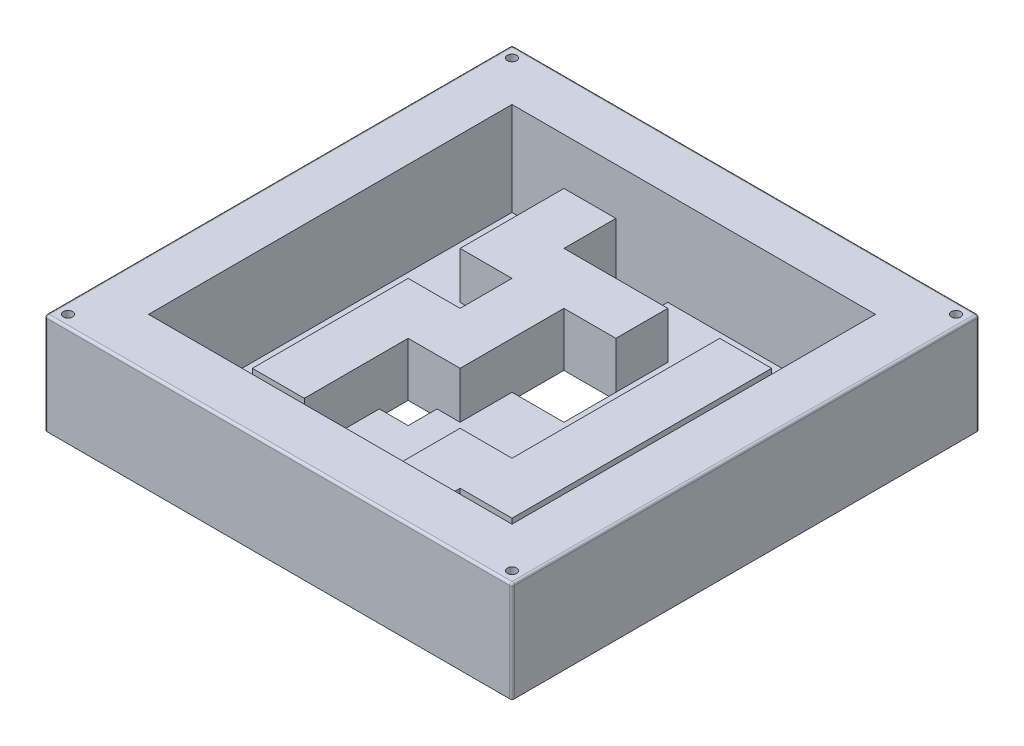
from build123d import *

# Parameters (mm, degrees)
ESQUISSE2_W             = 200
ESQUISSE2_H             = 200
BOSS_EXTRU_1_DEPTH      = 3
ESQUISSE3_W             = 200
ESQUISSE3_H             = 200
ESQUISSE3_W_2           = 155.54
ESQUISSE3_H_2           = 155.54
BOSS_EXTRU_2_DEPTH      = 40
BOSS_EXTRU_3_DEPTH      = 20
ENL_V_MAT_EXTRU_1_REACH = 5
ESQUISSE5_W             = 22.22
ESQUISSE5_H             = 22.22
ESQUISSE5_W_2           = 12.35
ESQUISSE5_H_2           = 12.35
CONG_1_R                = 1
ESQUISSE6_R             = 1
ENL_V_MAT_EXTRU_2_DEPTH = 44
ESQUISSE7_R             = 2
ENL_V_MAT_EXTRU_3_DEPTH = 41


with BuildPart() as part:
    # Esquisse2 → Boss.-Extru.1 (new body)
    with BuildSketch(Plane(origin=(0, 0, 0), x_dir=(1, 0, 0), z_dir=(0, 1, 0))):
        Rectangle(ESQUISSE2_W, ESQUISSE2_H)
    extrude(amount=-BOSS_EXTRU_1_DEPTH)

    # Esquisse3 → Boss.-Extru.2 (add)
    with BuildSketch(Plane(origin=(0, 0, 0), x_dir=(1, 0, 0), z_dir=(0, 1, 0))):
        Rectangle(ESQUISSE3_W, ESQUISSE3_H)
        Rectangle(ESQUISSE3_W_2, ESQUISSE3_H_2, mode=Mode.SUBTRACT)
    extrude(amount=BOSS_EXTRU_2_DEPTH)

    # Esquisse4 → Boss.-Extru.3 (add)
    with BuildSketch(Plane(origin=(0, 0, 0), x_dir=(1, 0, 0), z_dir=(0, 1, 0))):
        Polygon((-55.55, 77.77), (-33.33, 77.77), (-33.33, 55.55), (11.11, 55.55), (11.11, 33.33), (-11.11, 33.33), (-11.11, -11.11), (-33.33, -11.11), (-33.33, -55.55), (-55.55, -55.55), (-55.55, 11.11), (-33.33, 11.11), (-33.33, 33.33), (-55.55, 33.33), align=None)
        Polygon((33.33, 55.55), (55.55, 55.55), (55.55, -55.55), (33.33, -55.55), (33.33, -77.77), (11.11, -77.77), (11.11, -33.33), (33.33, -33.33), align=None)
    extrude(amount=BOSS_EXTRU_3_DEPTH)

    # Esquisse5 → Enlèv. mat.-Extru.1 (cut, up to next)
    with BuildSketch(Plane(origin=(0, 0, 0), x_dir=(1, 0, 0), z_dir=(0, 1, 0)), mode=Mode.PRIVATE) as enl_v_mat_extru_1_sk1:
        with Locations((-22.22, 66.66)):
            Rectangle(ESQUISSE5_W, ESQUISSE5_H)
    enl_v_mat_extru_1_tool1 = extrude(enl_v_mat_extru_1_sk1.sketch, amount=-ENL_V_MAT_EXTRU_1_REACH, mode=Mode.PRIVATE) & part.part
    add(enl_v_mat_extru_1_tool1.solids().sort_by_distance((-22.22, 0, -66.66))[0], mode=Mode.SUBTRACT)
    # Esquisse5 → Enlèv. mat.-Extru.1 (cut, up to next)
    with BuildSketch(Plane(origin=(0, 0, 0), x_dir=(1, 0, 0), z_dir=(0, 1, 0)), mode=Mode.PRIVATE) as enl_v_mat_extru_1_sk2:
        with Locations((0, 22.22)):
            Rectangle(ESQUISSE5_W, ESQUISSE5_H)
    enl_v_mat_extru_1_tool2 = extrude(enl_v_mat_extru_1_sk2.sketch, amount=-ENL_V_MAT_EXTRU_1_REACH, mode=Mode.PRIVATE) & part.part
    add(enl_v_mat_extru_1_tool2.solids().sort_by_distance((0, 0, -22.22))[0], mode=Mode.SUBTRACT)
    # Esquisse5 → Enlèv. mat.-Extru.1 (cut, up to next)
    with BuildSketch(Plane(origin=(0, 0, 0), x_dir=(1, 0, 0), z_dir=(0, 1, 0)), mode=Mode.PRIVATE) as enl_v_mat_extru_1_sk3:
        with Locations((-27.155, -17.285)):
            Rectangle(ESQUISSE5_W_2, ESQUISSE5_H_2)
    enl_v_mat_extru_1_tool3 = extrude(enl_v_mat_extru_1_sk3.sketch, amount=-ENL_V_MAT_EXTRU_1_REACH, mode=Mode.PRIVATE) & part.part
    add(enl_v_mat_extru_1_tool3.solids().sort_by_distance((-27.155, 0, 17.285))[0], mode=Mode.SUBTRACT)
    # Esquisse5 → Enlèv. mat.-Extru.1 (cut, up to next)
    with BuildSketch(Plane(origin=(0, 0, 0), x_dir=(1, 0, 0), z_dir=(0, 1, 0)), mode=Mode.PRIVATE) as enl_v_mat_extru_1_sk4:
        with Locations((-66.66, 22.22)):
            Rectangle(ESQUISSE5_W_2, ESQUISSE5_H_2)
    enl_v_mat_extru_1_tool4 = extrude(enl_v_mat_extru_1_sk4.sketch, amount=-ENL_V_MAT_EXTRU_1_REACH, mode=Mode.PRIVATE) & part.part
    add(enl_v_mat_extru_1_tool4.solids().sort_by_distance((-66.66, 0, -22.22))[0], mode=Mode.SUBTRACT)
    # Esquisse5 → Enlèv. mat.-Extru.1 (cut, up to next)
    with BuildSketch(Plane(origin=(0, 0, 0), x_dir=(1, 0, 0), z_dir=(0, 1, 0)), mode=Mode.PRIVATE) as enl_v_mat_extru_1_sk5:
        with Locations((-66.66, -66.66)):
            Rectangle(ESQUISSE5_W_2, ESQUISSE5_H_2)
    enl_v_mat_extru_1_tool5 = extrude(enl_v_mat_extru_1_sk5.sketch, amount=-ENL_V_MAT_EXTRU_1_REACH, mode=Mode.PRIVATE) & part.part
    add(enl_v_mat_extru_1_tool5.solids().sort_by_distance((-66.66, 0, 66.66))[0], mode=Mode.SUBTRACT)
    # Esquisse5 → Enlèv. mat.-Extru.1 (cut, up to next)
    with BuildSketch(Plane(origin=(0, 0, 0), x_dir=(1, 0, 0), z_dir=(0, 1, 0)), mode=Mode.PRIVATE) as enl_v_mat_extru_1_sk6:
        with Locations((66.66, -66.66)):
            Rectangle(ESQUISSE5_W_2, ESQUISSE5_H_2)
    enl_v_mat_extru_1_tool6 = extrude(enl_v_mat_extru_1_sk6.sketch, amount=-ENL_V_MAT_EXTRU_1_REACH, mode=Mode.PRIVATE) & part.part
    add(enl_v_mat_extru_1_tool6.solids().sort_by_distance((66.66, 0, 66.66))[0], mode=Mode.SUBTRACT)
    # Esquisse5 → Enlèv. mat.-Extru.1 (cut, up to next)
    with BuildSketch(Plane(origin=(0, 0, 0), x_dir=(1, 0, 0), z_dir=(0, 1, 0)), mode=Mode.PRIVATE) as enl_v_mat_extru_1_sk7:
        with Locations((4.935, -49.375)):
            Rectangle(ESQUISSE5_W_2, ESQUISSE5_H_2)
    enl_v_mat_extru_1_tool7 = extrude(enl_v_mat_extru_1_sk7.sketch, amount=-ENL_V_MAT_EXTRU_1_REACH, mode=Mode.PRIVATE) & part.part
    add(enl_v_mat_extru_1_tool7.solids().sort_by_distance((4.935, 0, 49.375))[0], mode=Mode.SUBTRACT)

    # Congé1
    cong_1_edges = [part.edges().sort_by_distance(p)[0] for p in [
        (-100, 40, 0),
        (0, 40, 100),
        (100, 40, 0),
        (0, 40, -100),
        (-100, 18.5, -100),
        (100, 18.5, -100),
        (100, 18.5, 100),
        (-100, 18.5, 100),
    ]]
    fillet(cong_1_edges, radius=CONG_1_R)

    # Esquisse6 → Enlèv. mat.-Extru.2 (cut, through all)
    with BuildSketch(Plane(origin=(0, 40, 0), x_dir=(1, 0, 0), z_dir=(0, 1, 0))):
        with Locations(Location((-95, -95, 0), (0, 0, 270))):  # turned: the seam where the file's is
            Circle(ESQUISSE6_R)
        with Locations(Location((95, -95, 0), (0, 0, 270))):  # turned: the seam where the file's is
            Circle(ESQUISSE6_R)
        with Locations(Location((95, 95, 0), (0, 0, 270))):  # turned: the seam where the file's is
            Circle(ESQUISSE6_R)
        with Locations(Location((-95, 95, 0), (0, 0, 270))):  # turned: the seam where the file's is
            Circle(ESQUISSE6_R)
    extrude(amount=-ENL_V_MAT_EXTRU_2_DEPTH, mode=Mode.SUBTRACT)

    # Esquisse7 → Enlèv. mat.-Extru.3 (cut)
    with BuildSketch(Plane(origin=(0, 40, 0), x_dir=(1, 0, 0), z_dir=(0, 1, 0))):
        with Locations(Location((-95, -95, 0), (0, 0, 270))):  # turned: the seam where the file's is
            Circle(ESQUISSE7_R)
        with Locations(Location((-95, 95, 0), (0, 0, 270))):  # turned: the seam where the file's is
            Circle(ESQUISSE7_R)
        with Locations(Location((95, 95, 0), (0, 0, 270))):  # turned: the seam where the file's is
            Circle(ESQUISSE7_R)
        with Locations(Location((95, -95, 0), (0, 0, 270))):  # turned: the seam where the file's is
            Circle(ESQUISSE7_R)
    extrude(amount=-ENL_V_MAT_EXTRU_3_DEPTH, mode=Mode.SUBTRACT)


solid = part.part
